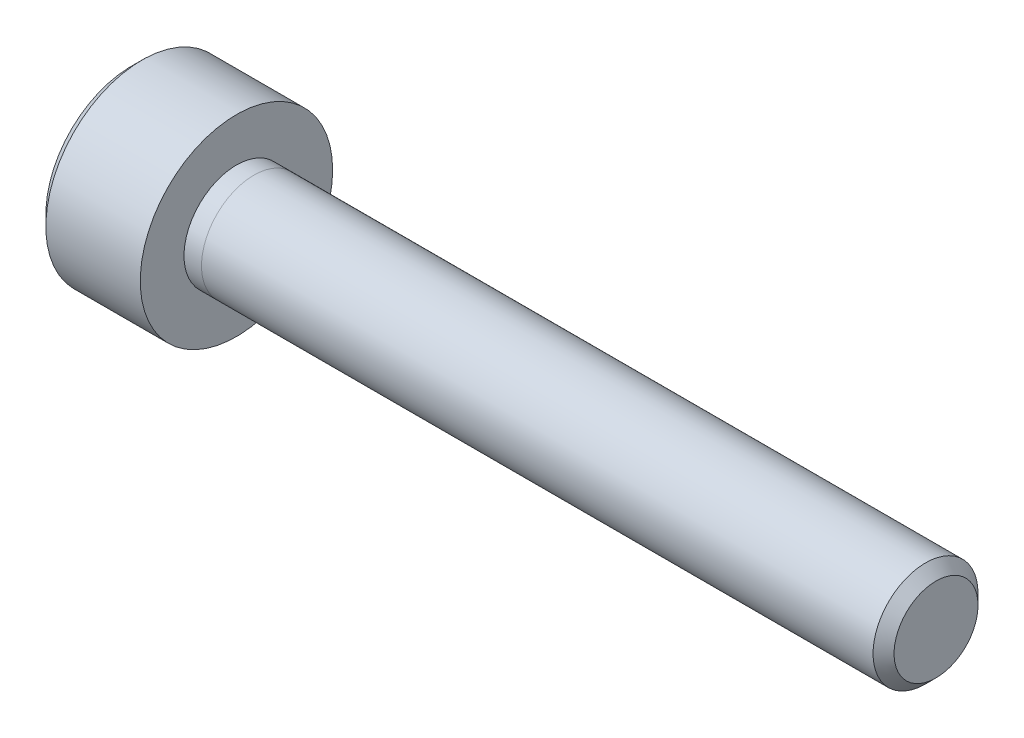
from build123d import *

# Parameters (mm, degrees)
SKETCH_1_R          = 2.75
EXTRUDE_1_DEPTH     = 3
SKETCH_2_R          = 1.5
EXTRUDE_2_DEPTH     = 0.5
CHAMFER_2_SIZE      = 0.3
CUT_EXTRUDE_1_DEPTH = 2.2
SKETCH_11_R         = 1.5
EXTRUDE_6_DEPTH     = 19.5
CHAMFER_3_SIZE      = 0.3


with BuildPart() as part:
    # 草图1 → 凸台-拉伸1 (new body)
    with BuildSketch(Plane(origin=(0, 0, 0), x_dir=(0, 0, -1), z_dir=(1, 0, 0))):
        Circle(SKETCH_1_R)
    extrude(amount=EXTRUDE_1_DEPTH)

    # 草图2 → 凸台-拉伸2 (add)
    with BuildSketch(Plane(origin=(3, 0, 0), x_dir=(0, 0, -1), z_dir=(1, 0, 0))):
        Circle(SKETCH_2_R)
    extrude(amount=EXTRUDE_2_DEPTH)

    # 倒角2
    chamfer_2_edges = [part.edges().sort_by_distance(p)[0] for p in [
        (0, 0, 2.75),
    ]]
    chamfer(chamfer_2_edges, length=CHAMFER_2_SIZE)

    # 草图5 → 切除-拉伸1 (cut)
    with BuildSketch(Plane.ZY):
        Polygon((1.430744137, 0.190537526), (0.550361731, 1.334329531), (-0.880382406, 1.143792006), (-1.430744137, -0.190537526), (-0.550361731, -1.334329531), (0.880382406, -1.143792006), align=None)
    extrude(amount=-CUT_EXTRUDE_1_DEPTH, mode=Mode.SUBTRACT)


with BuildPart() as body_2:
    # 草图11 → 凸台-拉伸6 (new body)
    with BuildSketch(Plane(origin=(3.5, 0, 0), x_dir=(0, 0, -1), z_dir=(1, 0, 0))):
        Circle(SKETCH_11_R)
    extrude(amount=EXTRUDE_6_DEPTH)

    # 倒角3
    chamfer_3_edges = [body_2.edges().sort_by_distance(p)[0] for p in [
        (23, 0, 1.5),
    ]]
    chamfer(chamfer_3_edges, length=CHAMFER_3_SIZE)


solid = Compound([part.part, body_2.part])
